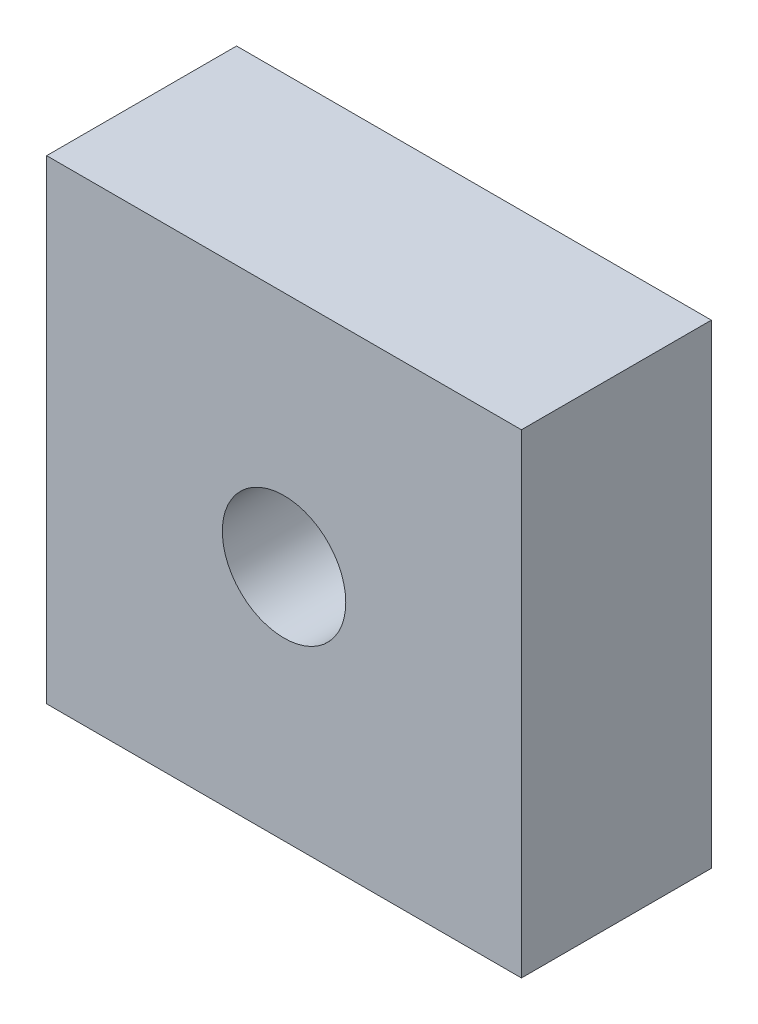
from build123d import *

# Parameters (mm, degrees)
SKETCH1_W           = 15
SKETCH1_H           = 15
SKETCH1_R           = 1.95
BOSS_EXTRUDE1_DEPTH = 6


with BuildPart() as part:
    # Sketch1 → Boss-Extrude1 (new body)
    with BuildSketch(Plane.XY):
        with Locations((7.5, 7.5)):
            Rectangle(SKETCH1_W, SKETCH1_H)
        with Locations((7.5, 7.5)):
            Circle(SKETCH1_R, mode=Mode.SUBTRACT)
    extrude(amount=BOSS_EXTRUDE1_DEPTH)


solid = part.part
